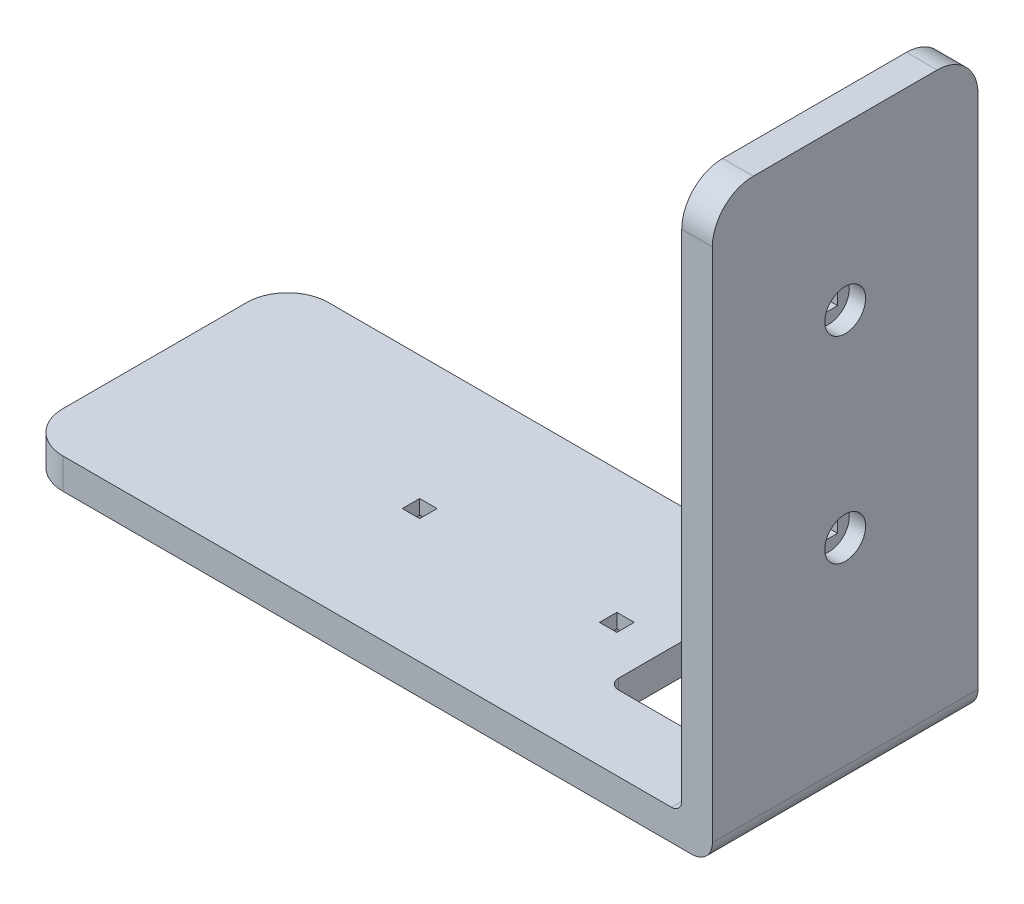
from build123d import *

# Parameters (mm, degrees)
EXTRUDE_1_DEPTH     = 3
SKETCH_2_W          = 3
SKETCH_2_H          = 26
EXTRUDE_2_DEPTH     = 53.5
FILLET_1_R          = 4
FILLET_2_R          = 2
FILLET_3_R          = 1
SKETCH_3_W          = 1.7
SKETCH_3_H          = 1.7
CUT_EXTRUDE_1_DEPTH = 3
SKETCH_4_R          = 2
CUT_EXTRUDE_2_DEPTH = 1.6
SKETCH_5_W          = 1.7
SKETCH_5_H          = 1.7
CUT_EXTRUDE_3_DEPTH = 3
SKETCH_6_R          = 2
CUT_EXTRUDE_4_DEPTH = 1.6
CUT_EXTRUDE_5_DEPTH = 3


with BuildPart() as part:
    # Эскиз1 → Бобышка-Вытянуть1 (new body)
    with BuildSketch(Plane(origin=(0, 0, 0), x_dir=(1, 0, 0), z_dir=(0, 1, 0))):
        with BuildLine():
            Line((-27.082461997, 18.034885268), (36.497538003, 18.034885268))
            Line((36.497538003, 18.034885268), (36.497538003, -7.965114732))
            Line((36.497538003, -7.965114732), (-27.082461997, -7.965114732))
            ThreePointArc((-27.082461997, -7.965114732), (-29.910889121, -6.793541857), (-31.082461997, -3.965114732))
            Line((-31.082461997, -3.965114732), (-31.082461997, 14.034885268))
            ThreePointArc((-31.082461997, 14.034885268), (-29.910889121, 16.863312393), (-27.082461997, 18.034885268))
        make_face()
    extrude(amount=EXTRUDE_1_DEPTH)

    # Эскиз2 → Бобышка-Вытянуть2 (add)
    with BuildSketch(Plane(origin=(0, 3, 0), x_dir=(1, 0, 0), z_dir=(0, 1, 0))):
        with Locations((34.997538003, 5.034885268)):
            Rectangle(SKETCH_2_W, SKETCH_2_H)
    extrude(amount=EXTRUDE_2_DEPTH)

    # Скругление1
    fillet_1_edges = [part.edges().sort_by_distance(p)[0] for p in [
        (34.997538003, 56.5, -18.034885268),
        (34.997538003, 56.5, 7.965114732),
    ]]
    fillet(fillet_1_edges, radius=FILLET_1_R)

    # Скругление2
    fillet_2_edges = [part.edges().sort_by_distance(p)[0] for p in [
        (36.497538003, 0, -5.034885268),
    ]]
    fillet(fillet_2_edges, radius=FILLET_2_R)

    # Скругление3
    fillet_3_edges = [part.edges().sort_by_distance(p)[0] for p in [
        (33.497538003, 3, -5.034885268),
    ]]
    fillet(fillet_3_edges, radius=FILLET_3_R)

    # Эскиз3 → Вырез-Вытянуть1 (cut)
    with BuildSketch(Plane.XZ):
        with Locations((-5.152461997, -5.034885268)):
            Rectangle(SKETCH_3_W, SKETCH_3_H)
        with Locations((14.147538003, -5.034885268)):
            Rectangle(SKETCH_3_W, SKETCH_3_H)
    extrude(amount=-CUT_EXTRUDE_1_DEPTH, mode=Mode.SUBTRACT)

    # Эскиз4 → Вырез-Вытянуть2 (cut)
    with BuildSketch(Plane.XZ):
        with Locations((-5.152461997, -5.034885268)):
            Circle(SKETCH_4_R)
        with Locations((14.147538003, -5.034885268)):
            Circle(SKETCH_4_R)
    extrude(amount=-CUT_EXTRUDE_2_DEPTH, mode=Mode.SUBTRACT)

    # Эскиз5 → Вырез-Вытянуть3 (cut)
    with BuildSketch(Plane(origin=(36.497538003, 0, 0), x_dir=(0, 0, -1), z_dir=(1, 0, 0))):
        with Locations((5.034885268, 21.35)):
            Rectangle(SKETCH_5_W, SKETCH_5_H)
        with Locations((5.034885268, 40.65)):
            Rectangle(SKETCH_5_W, SKETCH_5_H)
    extrude(amount=-CUT_EXTRUDE_3_DEPTH, mode=Mode.SUBTRACT)

    # Эскиз6 → Вырез-Вытянуть4 (cut)
    with BuildSketch(Plane(origin=(36.497538003, 0, 0), x_dir=(0, 0, -1), z_dir=(1, 0, 0))):
        with Locations((5.034885268, 40.65)):
            Circle(SKETCH_6_R)
        with Locations((5.034885268, 21.35)):
            Circle(SKETCH_6_R)
    extrude(amount=-CUT_EXTRUDE_4_DEPTH, mode=Mode.SUBTRACT)

    # Эскиз7 → Вырез-Вытянуть5 (cut)
    with BuildSketch(Plane.XZ):
        with BuildLine():
            Line((19.957538003, 0.615114732), (26.257538003, 0.615114732))
            ThreePointArc((26.257538003, 0.615114732), (26.964644784, 0.322221513), (27.257538003, -0.384885268))
            Line((27.257538003, -0.384885268), (27.257538003, -9.684885268))
            ThreePointArc((27.257538003, -9.684885268), (26.964644784, -10.391992049), (26.257538003, -10.684885268))
            Line((26.257538003, -10.684885268), (19.957538003, -10.684885268))
            ThreePointArc((19.957538003, -10.684885268), (19.250431222, -10.391992049), (18.957538003, -9.684885268))
            Line((18.957538003, -9.684885268), (18.957538003, -0.384885268))
            ThreePointArc((18.957538003, -0.384885268), (19.250431222, 0.322221513), (19.957538003, 0.615114732))
        make_face()
    extrude(amount=-CUT_EXTRUDE_5_DEPTH, mode=Mode.SUBTRACT)


solid = part.part
